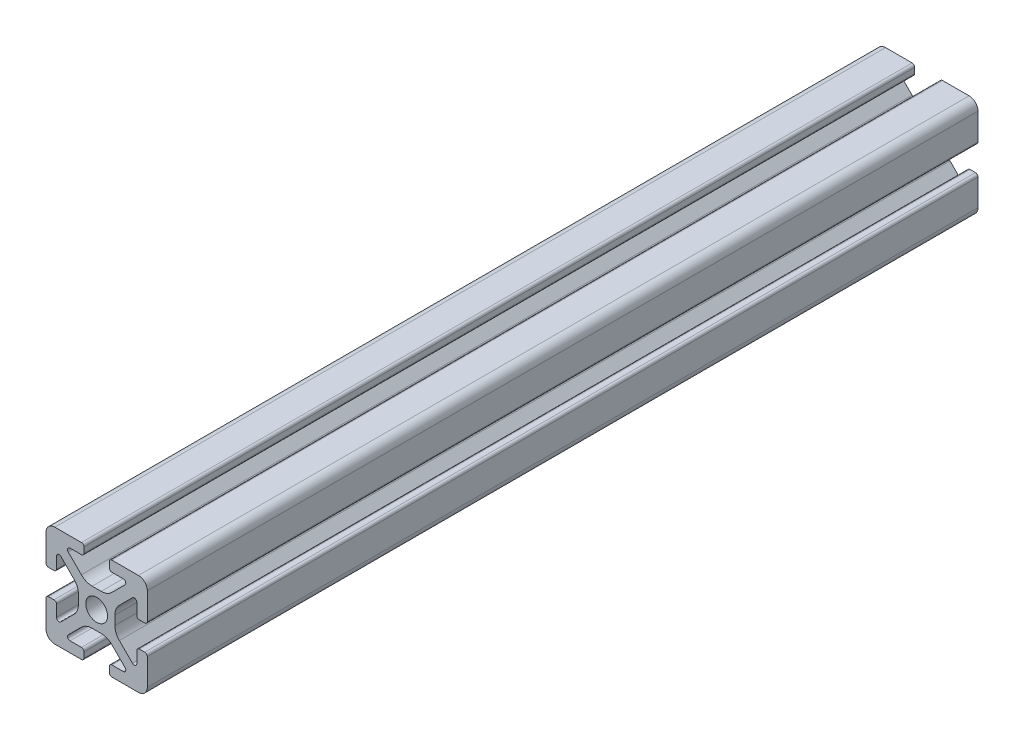
from build123d import *

# Parameters (mm, degrees)
BOSS_EXTRUDE1_DEPTH = 82


with BuildPart() as part:
    # Sketch4 → Boss-Extrude1 (new body, symmetric)
    with BuildSketch(Plane.XY):
        with BuildLine():
            Line((3, -10), (8.25, -10))
            ThreePointArc((8.25, -10), (9.487436867, -9.487436867), (10, -8.25))
            Line((10, -8.25), (10, -3))
            ThreePointArc((10, -3), (9.853553391, -2.646446609), (9.5, -2.5))
            Line((9.5, -2.5), (8.424621202, -2.5))
            ThreePointArc((8.424621202, -2.5), (8.071067812, -2.646446609), (7.924621202, -3))
            Line((7.924621202, -3), (7.924621202, -5.25))
            ThreePointArc((7.924621202, -5.25), (7.615962919, -5.711939766), (7.071067812, -5.603553391))
            Line((7.071067812, -5.603553391), (4.478679656, -3.011165235))
            ThreePointArc((4.478679656, -3.011165235), (3.828361402, -2.037895189), (3.6, -0.889844892))
            Line((3.6, -0.889844892), (3.6, 0))
            Line((3.6, 0), (2.15, 0))
            ThreePointArc((2.15, 0), (1.52027958, -1.52027958), (0, -2.15))
            Line((0, -2.15), (0, -3.6))
            Line((0, -3.6), (0.889844892, -3.6))
            ThreePointArc((0.889844892, -3.6), (2.037895189, -3.828361402), (3.011165235, -4.478679656))
            Line((3.011165235, -4.478679656), (5.603553391, -7.071067812))
            ThreePointArc((5.603553391, -7.071067812), (5.711939766, -7.615962919), (5.25, -7.924621202))
            Line((5.25, -7.924621202), (3, -7.924621202))
            ThreePointArc((3, -7.924621202), (2.646446609, -8.071067812), (2.5, -8.424621202))
            Line((2.5, -8.424621202), (2.5, -9.5))
            ThreePointArc((2.5, -9.5), (2.646446609, -9.853553391), (3, -10))
        make_face()
    extrude(amount=BOSS_EXTRUDE1_DEPTH, both=True)

    # Mirror1: part across plane


with BuildPart() as part_1:
    add(part.part)
    add(part.part.mirror(Plane(origin=(0, 0, 0), x_dir=(0, 0, 1), z_dir=(1, 0, 0))))

    # Mirror2: part across plane


with BuildPart() as part_2:
    add(part_1.part)
    add(part_1.part.mirror(Plane.ZX))


solid = part_2.part
